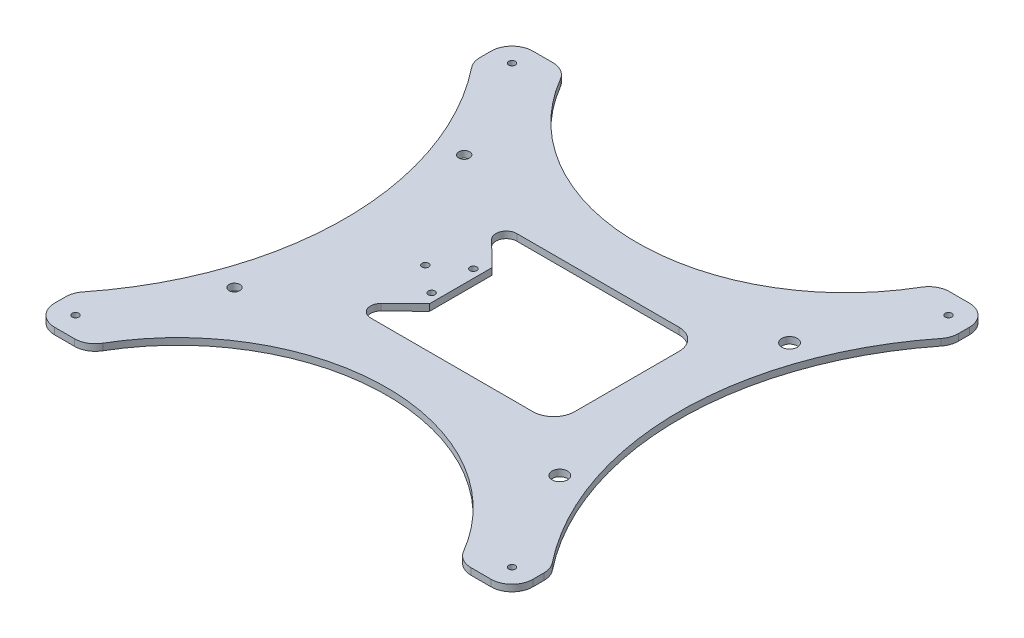
from build123d import *

# Parameters (mm, degrees)
SKETCH1_R           = 3.7
SKETCH1_R_2         = 1.6
SKETCH1_R_3         = 2.6
SKETCH1_W           = 110
SKETCH1_H           = 70
BOSS_EXTRUDE1_DEPTH = 3.175
FILLET1_R           = 10
CUT_EXTRUDE1_DEPTH  = 3.175
SKETCH3_3_R         = 1.6
BOSS_EXTRUDE2_DEPTH = 3.175
SKETCH4_R           = 1.6
BOSS_EXTRUDE3_DEPTH = 3.175
FILLET2_R           = 5


with BuildPart() as part:
    # Sketch1 → Boss-Extrude1 (new body)
    with BuildSketch(Plane(origin=(0, 0, 0), x_dir=(1, 0, 0), z_dir=(0, 1, 0))):
        with BuildLine():
            Line((-114.5, 114.5), (-114.5, 95.706582846))
            ThreePointArc((-114.5, 95.706582846), (-80, 0), (-114.5, -95.706582846))
            Line((-114.5, -95.706582846), (-114.5, -114.5))
            Line((-114.5, -114.5), (-89.049143735, -114.5))
            ThreePointArc((-89.049143735, -114.5), (-58.383323853, -78.812639556), (-14.791551643, -61.1))
            ThreePointArc((-14.791551643, -61.1), (0, -65), (14.791551643, -61.1))
            ThreePointArc((14.791551643, -61.1), (58.383323853, -78.812639556), (89.049143735, -114.5))
            Line((89.049143735, -114.5), (114.5, -114.5))
            Line((114.5, -114.5), (114.5, -95.706582846))
            ThreePointArc((114.5, -95.706582846), (80, 0), (114.5, 95.706582846))
            Line((114.5, 95.706582846), (114.5, 114.5))
            Line((114.5, 114.5), (89.049143735, 114.5))
            ThreePointArc((89.049143735, 114.5), (58.383323853, 78.812639556), (14.791551643, 61.1))
            ThreePointArc((14.791551643, 61.1), (0, 65), (-14.791551643, 61.1))
            ThreePointArc((-14.791551643, 61.1), (-58.383323853, 78.812639556), (-89.049143735, 114.5))
            Line((-89.049143735, 114.5), (-114.5, 114.5))
        make_face()
        with Locations((77.9, 55)):
            Circle(SKETCH1_R, mode=Mode.SUBTRACT)
        with Locations((-10, 50)):
            Circle(SKETCH1_R_2, mode=Mode.SUBTRACT)
        with Locations((-104.5, 104.5)):
            Circle(SKETCH1_R_2, mode=Mode.SUBTRACT)
        with Locations((-5, 60)):
            Circle(SKETCH1_R_2, mode=Mode.SUBTRACT)
        with Locations((77.9, -55)):
            Circle(SKETCH1_R, mode=Mode.SUBTRACT)
        with Locations((-77.9, 55)):
            Circle(SKETCH1_R_3, mode=Mode.SUBTRACT)
        with Locations((-104.5, -104.5)):
            Circle(SKETCH1_R_2, mode=Mode.SUBTRACT)
        with Locations((-77.9, -55)):
            Circle(SKETCH1_R_3, mode=Mode.SUBTRACT)
        with Locations((-10, -50)):
            Circle(SKETCH1_R_2, mode=Mode.SUBTRACT)
        with Locations((-5, -60)):
            Circle(SKETCH1_R_2, mode=Mode.SUBTRACT)
        with Locations((104.5, -104.5)):
            Circle(SKETCH1_R_2, mode=Mode.SUBTRACT)
        with Locations((5, -60)):
            Circle(SKETCH1_R_2, mode=Mode.SUBTRACT)
        with Locations((10, -50)):
            Circle(SKETCH1_R_2, mode=Mode.SUBTRACT)
        with Locations((104.5, 104.5)):
            Circle(SKETCH1_R_2, mode=Mode.SUBTRACT)
        with Locations((10, 50)):
            Circle(SKETCH1_R_2, mode=Mode.SUBTRACT)
        with Locations((5, 60)):
            Circle(SKETCH1_R_2, mode=Mode.SUBTRACT)
        Rectangle(SKETCH1_W, SKETCH1_H, mode=Mode.SUBTRACT)
    extrude(amount=BOSS_EXTRUDE1_DEPTH)

    # Fillet1
    fillet1_edges = [part.edges().sort_by_distance(p)[0] for p in [
        (-114.5, 1.5875, 114.5),
        (-114.5, 1.5875, 95.706582846),
        (-114.5, 1.5875, -95.706582846),
        (-114.5, 1.5875, -114.5),
        (-89.049143735, 1.5875, -114.5),
        (-14.791551643, 1.5875, -61.1),
        (14.791551643, 1.5875, -61.1),
        (89.049143735, 1.5875, -114.5),
        (114.5, 1.5875, -114.5),
        (114.5, 1.5875, -95.706582846),
        (114.5, 1.5875, 95.706582846),
        (114.5, 1.5875, 114.5),
        (89.049143735, 1.5875, 114.5),
        (14.791551643, 1.5875, 61.1),
        (-14.791551643, 1.5875, 61.1),
        (-89.049143735, 1.5875, 114.5),
        (-55, 1.5875, -35),
        (-55, 1.5875, 35),
        (55, 1.5875, 35),
        (55, 1.5875, -35),
    ]]
    fillet(fillet1_edges, radius=FILLET1_R)

    # Sketch3 → Cut-Extrude1 (cut)
    with BuildSketch(Plane(origin=(0, 3.175, 0), x_dir=(1, 0, 0), z_dir=(0, 1, 0))):
        with BuildLine():
            Line((-86.338513092, -109.545454545), (86.338513092, -109.545454545))
            ThreePointArc((86.338513092, -109.545454545), (57.482053735, -78.172049406), (18.181186858, -61.666666667))
            ThreePointArc((18.181186858, -61.666666667), (-41.646726907, -69.084928983), (-86.338513092, -109.545454545))
        make_face()
        with BuildLine():
            Line((-86.338513092, 109.545454545), (86.338513092, 109.545454545))
            ThreePointArc((86.338513092, 109.545454545), (57.482053735, 78.172049406), (18.181186858, 61.666666667))
            ThreePointArc((18.181186858, 61.666666667), (-41.646726907, 69.084928983), (-86.338513092, 109.545454545))
        make_face()
    extrude(amount=-CUT_EXTRUDE1_DEPTH, mode=Mode.SUBTRACT)

    # Sketch3_3 → Boss-Extrude2 (add)
    with BuildSketch(Plane(origin=(0, 3.175, 0), x_dir=(1, 0, 0), z_dir=(0, 1, 0))):
        with BuildLine():
            ThreePointArc((-3.401046245, -60.057852312), (-5.079900187, -58.401996258), (-6.585208119, -60.217060406))
            ThreePointArc((-6.585208119, -60.217060406), (-4.993761694, -60.124766112), (-3.401046245, -60.057852312))
        make_face()
        with BuildLine():
            ThreePointArc((3.401046245, -60.057852312), (4.993761694, -60.124766112), (6.585208119, -60.217060406))
            ThreePointArc((6.585208119, -60.217060406), (5.079900187, -58.401996258), (3.401046245, -60.057852312))
        make_face()
        with BuildLine():
            ThreePointArc((-3.401046245, 60.057852312), (-4.993761694, 60.124766112), (-6.585208119, 60.217060406))
            ThreePointArc((-6.585208119, 60.217060406), (-5.079900187, 58.401996258), (-3.401046245, 60.057852312))
        make_face()
        with BuildLine():
            ThreePointArc((3.401046245, 60.057852312), (5.079900187, 58.401996258), (6.585208119, 60.217060406))
            ThreePointArc((6.585208119, 60.217060406), (4.993761694, 60.124766112), (3.401046245, 60.057852312))
        make_face()
        with Locations((10, 50)):
            Circle(SKETCH3_3_R)
        with Locations((-10, 50)):
            Circle(SKETCH3_3_R)
        with Locations((-10, -50)):
            Circle(SKETCH3_3_R)
        with Locations((10, -50)):
            Circle(SKETCH3_3_R)
    extrude(amount=-BOSS_EXTRUDE2_DEPTH)

    # Sketch4 → Boss-Extrude3 (add)
    with BuildSketch(Plane(origin=(0, 3.175, 0), x_dir=(1, 0, 0), z_dir=(0, 1, 0))):
        with BuildLine():
            Line((-24.5, -15), (-24.5, 15))
            Line((-24.5, 15), (-45, 35))
            ThreePointArc((-45, 35), (-52.071067812, 32.071067812), (-55, 25))
            Line((-55, 25), (-55, -25))
            ThreePointArc((-55, -25), (-52.071067812, -32.071067812), (-45, -35))
            Line((-45, -35), (-24.5, -15))
        make_face()
        with Locations((-28.5, 10)):
            Circle(SKETCH4_R, mode=Mode.SUBTRACT)
        with Locations((-28.5, -10)):
            Circle(SKETCH4_R, mode=Mode.SUBTRACT)
        with Locations((-41.5, 0)):
            Circle(SKETCH4_R, mode=Mode.SUBTRACT)
    extrude(amount=-BOSS_EXTRUDE3_DEPTH)

    # Fillet2
    fillet2_edges = [part.edges().sort_by_distance(p)[0] for p in [
        (-45, 1.5875, 35),
        (-45, 1.5875, -35),
    ]]
    fillet(fillet2_edges, radius=FILLET2_R)


solid = part.part
